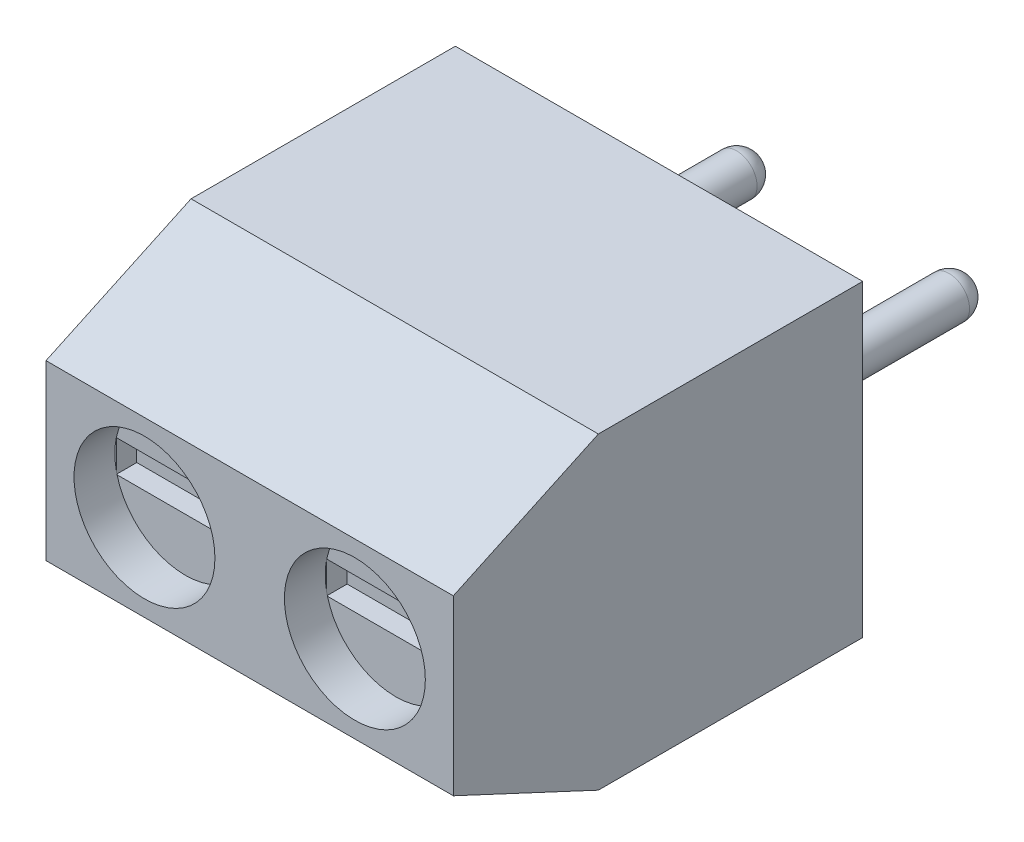
from build123d import *

# Parameters (mm, degrees)
ESQUISSE1_W             = 9.97
ESQUISSE1_H             = 7.55
EXTRUSION1_DEPTH        = 10.02
CHANFREIN1_SIZE2        = 1.655392186
CHANFREIN1_SIZE         = 3.55
ESQUISSE2_R             = 1.725
ENL_V_MAT_EXTRU_1_DEPTH = 1
ESQUISSE3_W             = 4
ESQUISSE3_H             = 5
ENL_V_MAT_EXTRU_2_DEPTH = 1.6
ESQUISSE4_R             = 1.675
ENL_V_MAT_EXTRU_3_DEPTH = 1.6
ESQUISSE5_R             = 0.5
EXTRUSION2_DEPTH        = 5
CONG_1_R                = 0.5
ESQUISSE7_W             = 3.359641585
ESQUISSE7_H             = 0.780050821
ENL_V_MAT_EXTRU_4_DEPTH = 0.5
ESQUISSE8_W             = 3.1960084
ESQUISSE8_H             = 1.003036954
ENL_V_MAT_EXTRU_5_DEPTH = 0.5


with BuildPart() as part:
    # Esquisse1 → Extrusion1 (new body)
    with BuildSketch(Plane.XY):
        with Locations((4.985, 3.775)):
            Rectangle(ESQUISSE1_W, ESQUISSE1_H)
    extrude(amount=EXTRUSION1_DEPTH)

    # Chanfrein1
    chanfrein1_edges = [part.edges().sort_by_distance(p)[0] for p in [
        (4.985, 7.55, 10.02),
        (4.985, 0, 10.02),
    ]]
    chamfer(chanfrein1_edges, length=CHANFREIN1_SIZE, length2=CHANFREIN1_SIZE2)

    # Esquisse2 → Enlèv. mat.-Extru.1 (cut)
    with BuildSketch(Plane.XY.offset(10.02)):
        with Locations((2.410120412, 3.775)):
            Circle(ESQUISSE2_R)
        with Locations((7.559879588, 3.775)):
            Circle(ESQUISSE2_R)
    extrude(amount=-ENL_V_MAT_EXTRU_1_DEPTH, mode=Mode.SUBTRACT)

    # Esquisse3 → Enlèv. mat.-Extru.2 (cut)
    with BuildSketch(Plane.XZ):
        with Locations((7.435, 3.3)):
            Rectangle(ESQUISSE3_W, ESQUISSE3_H)
        with Locations((2.535, 3.3)):
            Rectangle(ESQUISSE3_W, ESQUISSE3_H)
    extrude(amount=-ENL_V_MAT_EXTRU_2_DEPTH, mode=Mode.SUBTRACT)

    # Esquisse4 → Enlèv. mat.-Extru.3 (cut)
    with BuildSketch(Plane.XZ.offset(-1.6)):
        with Locations(Location((7.435, 3.235, 0), (0, 0, 270))):  # turned: the seam where the file's is
            Circle(ESQUISSE4_R)
        with Locations(Location((2.535, 3.235, 0), (0, 0, 270))):  # turned: the seam where the file's is
            Circle(ESQUISSE4_R)
    extrude(amount=-ENL_V_MAT_EXTRU_3_DEPTH, mode=Mode.SUBTRACT)

    # Esquisse5 → Extrusion2 (add)
    with BuildSketch(Plane(origin=(0, 0, 0), x_dir=(-1, 0, 0), z_dir=(0, 0, -1))):
        with Locations((-7.585, 3.775)):
            Circle(ESQUISSE5_R)
        with Locations((-2.385, 3.775)):
            Circle(ESQUISSE5_R)
    extrude(amount=EXTRUSION2_DEPTH)

    # Congé1
    cong_1_edges = [part.edges().sort_by_distance(p)[0] for p in [
        (8.085, 3.775, -5),
        (2.885, 3.775, -5),
    ]]
    fillet(cong_1_edges, radius=CONG_1_R)

    # Esquisse7 → Enlèv. mat.-Extru.4 (cut)
    with BuildSketch(Plane.XY.offset(9.02)):
        with Locations((2.40077537, 3.734751354)):
            Rectangle(ESQUISSE7_W, ESQUISSE7_H)
        with Locations((7.550534547, 3.734751354)):
            Rectangle(ESQUISSE7_W, ESQUISSE7_H)
    extrude(amount=-ENL_V_MAT_EXTRU_4_DEPTH, mode=Mode.SUBTRACT)

    # Esquisse8 → Enlèv. mat.-Extru.5 (cut)
    with BuildSketch(Plane.XZ.offset(-3.2)):
        with Locations((2.54160667, 3.256051041)):
            Rectangle(ESQUISSE8_W, ESQUISSE8_H)
        with Locations((7.44160667, 3.256051041)):
            Rectangle(ESQUISSE8_W, ESQUISSE8_H)
    extrude(amount=-ENL_V_MAT_EXTRU_5_DEPTH, mode=Mode.SUBTRACT)


solid = part.part
